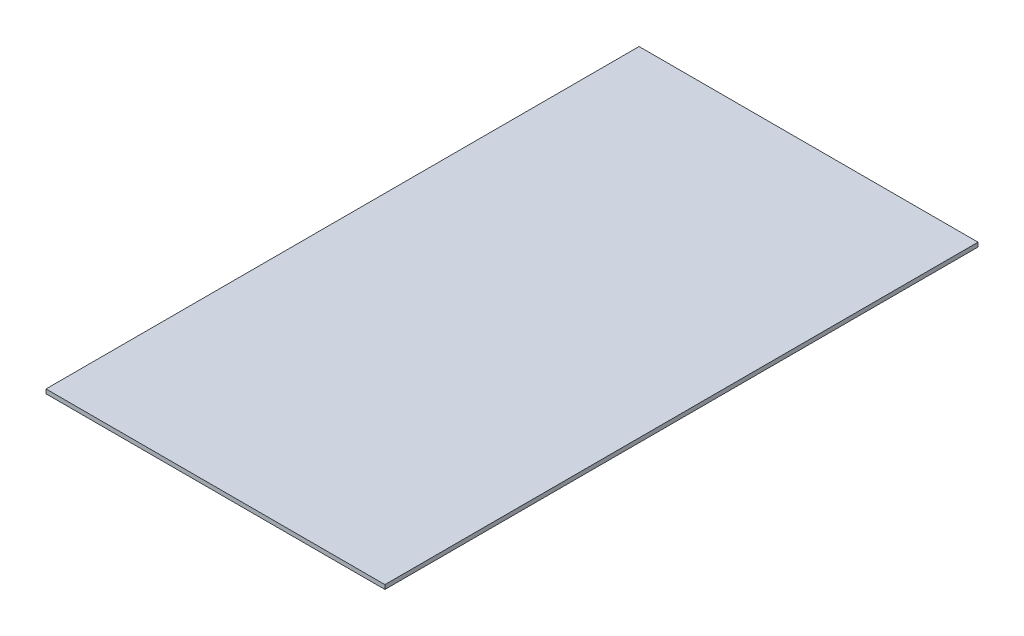
from build123d import *

# Parameters (mm, degrees)
SKETCH1_W           = 400
SKETCH1_H           = 700
BOSS_EXTRUDE1_DEPTH = 5


with BuildPart() as part:
    # Sketch1 → Boss-Extrude1 (new body)
    with BuildSketch(Plane(origin=(0, 0, 0), x_dir=(1, 0, 0), z_dir=(0, 1, 0))):
        Rectangle(SKETCH1_W, SKETCH1_H)
    extrude(amount=BOSS_EXTRUDE1_DEPTH)


solid = part.part
